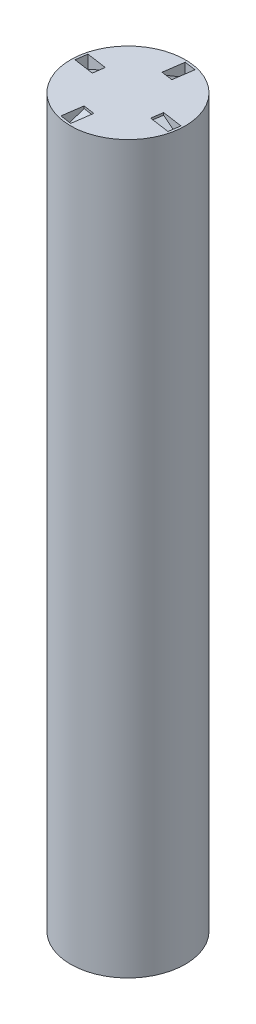
from build123d import *

# Parameters (mm, degrees)
SKETCH1_R           = 6.395
BOSS_EXTRUDE1_DEPTH = 80.99
SKETCH3_W           = 6.14
SKETCH3_H           = 3.7
CUT_EXTRUDE2_DEPTH  = 8.5
CUT_EXTRUDE3_DEPTH  = 1.28
CIRPATTERN1_COUNT   = 4


with BuildPart() as part:
    # Sketch1 → Boss-Extrude1 (new body)
    with BuildSketch(Plane(origin=(0, 0, 0), x_dir=(1, 0, 0), z_dir=(0, 1, 0))):
        Circle(SKETCH1_R)
    extrude(amount=BOSS_EXTRUDE1_DEPTH)

    # Sketch3 → Cut-Extrude2 (cut)
    with BuildSketch(Plane.XZ):
        Rectangle(SKETCH3_W, SKETCH3_H)
    extrude(amount=-CUT_EXTRUDE2_DEPTH, mode=Mode.SUBTRACT)

    # Sketch4 → Cut-Extrude3 (cut)
    with BuildSketch(Plane(origin=(-0.091269963, 0, 0.633458597), x_dir=(0.989779057, 0, 0.142609318), z_dir=(-0.142609318, 0, 0.989779057))):
        Polygon((-3.84099181, 80.99), (-6.12099181, 80.99), (-6.12099181, 79.513663006), (-3.84099181, 80.733663006), align=None)
    cut_extrude3 = extrude(amount=-CUT_EXTRUDE3_DEPTH, mode=Mode.SUBTRACT)

    # CirPattern1: Cut-Extrude3 ×4 about axis
    cirpattern1_axis = Axis((0, 0, 0), (0, 1, 0))
    for i in range(1, CIRPATTERN1_COUNT):
        add(cut_extrude3.rotate(cirpattern1_axis, i * 360 / CIRPATTERN1_COUNT), mode=Mode.SUBTRACT)


solid = part.part
